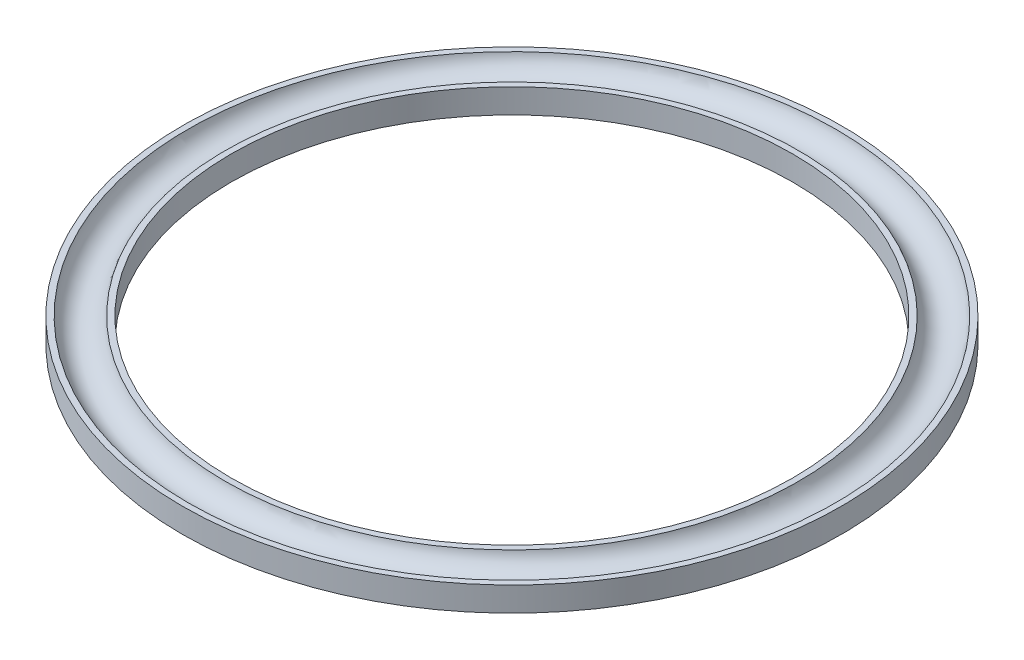
from build123d import *

# Parameters (mm, degrees)
SKETCH4_W          = 0.681153679
SKETCH4_H          = 0.530582866
CUT_EXTRUDE1_DEPTH = 0.3


with BuildPart() as part:
    # Sketch2 → Revolve2 (revolve)
    with BuildSketch(Plane.XY):
        with BuildLine():
            Line((-46, -4.2), (-46, -6.7))
            Line((-46, -6.7), (-46, -8.2))
            Line((-46, -8.2), (-54, -8.2))
            Line((-54, -8.2), (-54, -4.2))
            Line((-54, -4.2), (-53.041381265, -4.2))
            ThreePointArc((-53.041381265, -4.2), (-50, -6.7), (-46.958618735, -4.2))
            Line((-46.958618735, -4.2), (-46, -4.2))
        make_face()
    revolve(axis=Axis((0, 30.712444699, 0), (0, -1, 0)))

    # Sketch4 → Cut-Extrude1 (cut)
    with BuildSketch(Plane.XZ.offset(8.2)):
        Polygon((-49.606287717, 0), (-51.284076779, 0), (-51.284076779, -1.569276179), (-50.086680312, -1.569276179), (-50.086680312, -3.017624002), (-49.606287717, -3.017624002), (-49.606287717, -1.569276179), align=None)
        with Locations((-50.427257152, -0.658681261)):
            Rectangle(SKETCH4_W, SKETCH4_H, mode=Mode.SUBTRACT)
        Polygon((-47.068094007, 0), (-48.889283844, 0), (-48.889283844, -0.708871532), (-48.129259739, -0.708871532), (-48.889283844, -3.017624002), (-47.828118112, -3.017624002), (-47.068094007, -0.708871532), align=None)
    extrude(amount=-CUT_EXTRUDE1_DEPTH, mode=Mode.SUBTRACT)


solid = part.part
